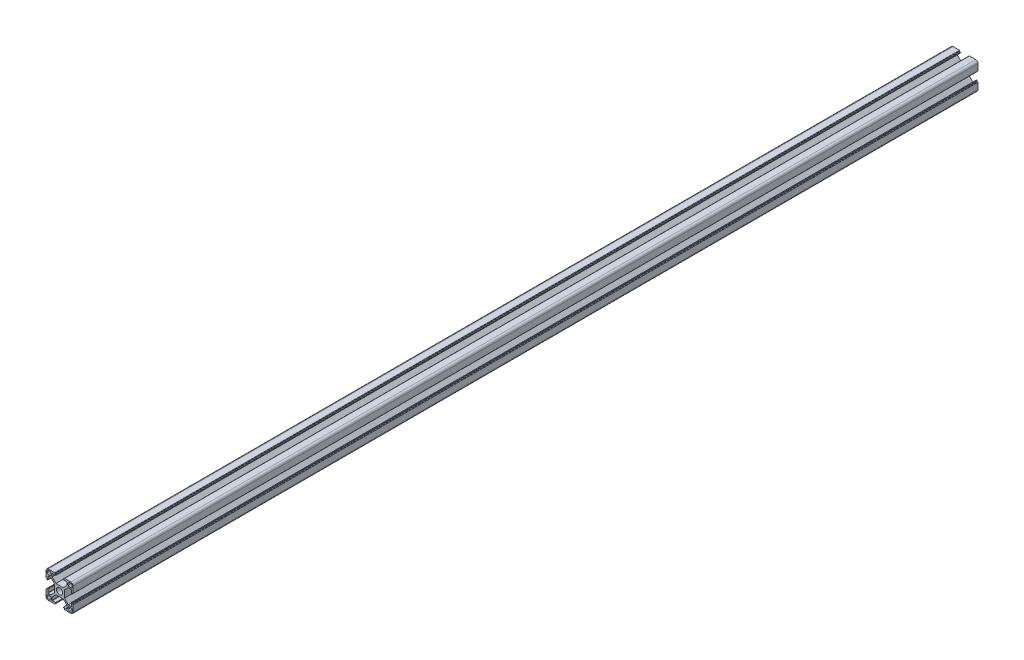
from build123d import *

# Parameters (mm, degrees)
SKETCH_1_R      = 3.4
EXTRUDE_1_DEPTH = 1000


with BuildPart() as part:
    # Эскиз1 → Бобышка-Вытянуть1 (new body)
    with BuildSketch(Plane.XY):
        with BuildLine():
            Line((-15, -8.25), (-15, -12.5))
            ThreePointArc((-15, -12.5), (-14.267766953, -14.267766953), (-12.5, -15))
            Line((-12.5, -15), (-8.25, -15))
            Line((-8.25, -15), (-5.5, -15))
            ThreePointArc((-5.5, -15), (-5.287867966, -14.912132034), (-5.2, -14.7))
            Line((-5.2, -14.7), (-5.2, -14.3))
            ThreePointArc((-5.2, -14.3), (-5.112132034, -14.087867966), (-4.9, -14))
            Line((-4.9, -14), (-4.4, -14))
            ThreePointArc((-4.4, -14), (-4.187867966, -13.912132034), (-4.1, -13.7))
            Line((-4.1, -13.7), (-4.1, -13.3))
            ThreePointArc((-4.1, -13.3), (-4.187867966, -13.087867966), (-4.4, -13))
            Line((-4.4, -13), (-7.95, -13))
            ThreePointArc((-7.95, -13), (-8.162132034, -12.912132034), (-8.25, -12.7))
            Line((-8.25, -12.7), (-8.25, -9.65))
            Line((-8.25, -9.65), (-4, -5.4))
            Line((-4, -5.4), (4, -5.4))
            Line((4, -5.4), (8.25, -9.65))
            Line((8.25, -9.65), (8.25, -12.7))
            ThreePointArc((8.25, -12.7), (8.162132034, -12.912132034), (7.95, -13))
            Line((7.95, -13), (4.4, -13))
            ThreePointArc((4.4, -13), (4.187867966, -13.087867966), (4.1, -13.3))
            Line((4.1, -13.3), (4.1, -13.7))
            ThreePointArc((4.1, -13.7), (4.187867966, -13.912132034), (4.4, -14))
            Line((4.4, -14), (4.9, -14))
            ThreePointArc((4.9, -14), (5.112132034, -14.087867966), (5.2, -14.3))
            Line((5.2, -14.3), (5.2, -14.7))
            ThreePointArc((5.2, -14.7), (5.287867966, -14.912132034), (5.5, -15))
            Line((5.5, -15), (8.25, -15))
            Line((8.25, -15), (12.5, -15))
            ThreePointArc((12.5, -15), (14.267766953, -14.267766953), (15, -12.5))
            Line((15, -12.5), (15, -8.25))
            Line((15, -8.25), (15, -5.5))
            ThreePointArc((15, -5.5), (14.912132034, -5.287867966), (14.7, -5.2))
            Line((14.7, -5.2), (14.3, -5.2))
            ThreePointArc((14.3, -5.2), (14.087867966, -5.112132034), (14, -4.9))
            Line((14, -4.9), (14, -4.4))
            ThreePointArc((14, -4.4), (13.912132034, -4.187867966), (13.7, -4.1))
            Line((13.7, -4.1), (13.3, -4.1))
            ThreePointArc((13.3, -4.1), (13.087867966, -4.187867966), (13, -4.4))
            Line((13, -4.4), (13, -7.95))
            ThreePointArc((13, -7.95), (12.912132034, -8.162132034), (12.7, -8.25))
            Line((12.7, -8.25), (9.65, -8.25))
            Line((9.65, -8.25), (5.4, -4))
            Line((5.4, -4), (5.4, 4))
            Line((5.4, 4), (9.65, 8.25))
            Line((9.65, 8.25), (12.7, 8.25))
            ThreePointArc((12.7, 8.25), (12.912132034, 8.162132034), (13, 7.95))
            Line((13, 7.95), (13, 4.4))
            ThreePointArc((13, 4.4), (13.087867966, 4.187867966), (13.3, 4.1))
            Line((13.3, 4.1), (13.7, 4.1))
            ThreePointArc((13.7, 4.1), (13.912132034, 4.187867966), (14, 4.4))
            Line((14, 4.4), (14, 4.9))
            ThreePointArc((14, 4.9), (14.087867966, 5.112132034), (14.3, 5.2))
            Line((14.3, 5.2), (14.7, 5.2))
            ThreePointArc((14.7, 5.2), (14.912132034, 5.287867966), (15, 5.5))
            Line((15, 5.5), (15, 8.25))
            Line((15, 8.25), (15, 12.5))
            ThreePointArc((15, 12.5), (14.267766953, 14.267766953), (12.5, 15))
            Line((12.5, 15), (8.25, 15))
            Line((8.25, 15), (5.5, 15))
            ThreePointArc((5.5, 15), (5.287867966, 14.912132034), (5.2, 14.7))
            Line((5.2, 14.7), (5.2, 14.3))
            ThreePointArc((5.2, 14.3), (5.112132034, 14.087867966), (4.9, 14))
            Line((4.9, 14), (4.4, 14))
            ThreePointArc((4.4, 14), (4.187867966, 13.912132034), (4.1, 13.7))
            Line((4.1, 13.7), (4.1, 13.3))
            ThreePointArc((4.1, 13.3), (4.187867966, 13.087867966), (4.4, 13))
            Line((4.4, 13), (7.95, 13))
            ThreePointArc((7.95, 13), (8.162132034, 12.912132034), (8.25, 12.7))
            Line((8.25, 12.7), (8.25, 9.65))
            Line((8.25, 9.65), (4, 5.4))
            Line((4, 5.4), (-4, 5.4))
            Line((-4, 5.4), (-8.25, 9.65))
            Line((-8.25, 9.65), (-8.25, 12.7))
            ThreePointArc((-8.25, 12.7), (-8.162132034, 12.912132034), (-7.95, 13))
            Line((-7.95, 13), (-4.4, 13))
            ThreePointArc((-4.4, 13), (-4.187867966, 13.087867966), (-4.1, 13.3))
            Line((-4.1, 13.3), (-4.1, 13.7))
            ThreePointArc((-4.1, 13.7), (-4.187867966, 13.912132034), (-4.4, 14))
            Line((-4.4, 14), (-4.9, 14))
            ThreePointArc((-4.9, 14), (-5.112132034, 14.087867966), (-5.2, 14.3))
            Line((-5.2, 14.3), (-5.2, 14.7))
            ThreePointArc((-5.2, 14.7), (-5.287867966, 14.912132034), (-5.5, 15))
            Line((-5.5, 15), (-8.25, 15))
            Line((-8.25, 15), (-12.5, 15))
            ThreePointArc((-12.5, 15), (-14.267766953, 14.267766953), (-15, 12.5))
            Line((-15, 12.5), (-15, 8.25))
            Line((-15, 8.25), (-15, 5.5))
            ThreePointArc((-15, 5.5), (-14.912132034, 5.287867966), (-14.7, 5.2))
            Line((-14.7, 5.2), (-14.3, 5.2))
            ThreePointArc((-14.3, 5.2), (-14.087867966, 5.112132034), (-14, 4.9))
            Line((-14, 4.9), (-14, 4.4))
            ThreePointArc((-14, 4.4), (-13.912132034, 4.187867966), (-13.7, 4.1))
            Line((-13.7, 4.1), (-13.3, 4.1))
            ThreePointArc((-13.3, 4.1), (-13.087867966, 4.187867966), (-13, 4.4))
            Line((-13, 4.4), (-13, 7.95))
            ThreePointArc((-13, 7.95), (-12.912132034, 8.162132034), (-12.7, 8.25))
            Line((-12.7, 8.25), (-9.65, 8.25))
            Line((-9.65, 8.25), (-5.4, 4))
            Line((-5.4, 4), (-5.4, -4))
            Line((-5.4, -4), (-9.65, -8.25))
            Line((-9.65, -8.25), (-12.7, -8.25))
            ThreePointArc((-12.7, -8.25), (-12.912132034, -8.162132034), (-13, -7.95))
            Line((-13, -7.95), (-13, -4.4))
            ThreePointArc((-13, -4.4), (-13.087867966, -4.187867966), (-13.3, -4.1))
            Line((-13.3, -4.1), (-13.7, -4.1))
            ThreePointArc((-13.7, -4.1), (-13.912132034, -4.187867966), (-14, -4.4))
            Line((-14, -4.4), (-14, -4.9))
            ThreePointArc((-14, -4.9), (-14.087867966, -5.112132034), (-14.3, -5.2))
            Line((-14.3, -5.2), (-14.7, -5.2))
            ThreePointArc((-14.7, -5.2), (-14.912132034, -5.287867966), (-15, -5.5))
            Line((-15, -5.5), (-15, -8.25))
        make_face()
        Circle(SKETCH_1_R, mode=Mode.SUBTRACT)
        with BuildLine():
            Line((-12.45, -9.55), (-10.85, -9.55))
            ThreePointArc((-10.85, -9.55), (-9.930761184, -9.930761184), (-9.55, -10.85))
            Line((-9.55, -10.85), (-9.55, -12.45))
            ThreePointArc((-9.55, -12.45), (-9.930761184, -13.369238816), (-10.85, -13.75))
            Line((-10.85, -13.75), (-12.45, -13.75))
            ThreePointArc((-12.45, -13.75), (-13.369238816, -13.369238816), (-13.75, -12.45))
            Line((-13.75, -12.45), (-13.75, -10.85))
            ThreePointArc((-13.75, -10.85), (-13.369238816, -9.930761184), (-12.45, -9.55))
        make_face(mode=Mode.SUBTRACT)
        with BuildLine():
            Line((-9.55, 12.45), (-9.55, 10.85))
            ThreePointArc((-9.55, 10.85), (-9.930761184, 9.930761184), (-10.85, 9.55))
            Line((-10.85, 9.55), (-12.45, 9.55))
            ThreePointArc((-12.45, 9.55), (-13.369238816, 9.930761184), (-13.75, 10.85))
            Line((-13.75, 10.85), (-13.75, 12.45))
            ThreePointArc((-13.75, 12.45), (-13.369238816, 13.369238816), (-12.45, 13.75))
            Line((-12.45, 13.75), (-10.85, 13.75))
            ThreePointArc((-10.85, 13.75), (-9.930761184, 13.369238816), (-9.55, 12.45))
        make_face(mode=Mode.SUBTRACT)
        with BuildLine():
            Line((12.45, 9.55), (10.85, 9.55))
            ThreePointArc((10.85, 9.55), (9.930761184, 9.930761184), (9.55, 10.85))
            Line((9.55, 10.85), (9.55, 12.45))
            ThreePointArc((9.55, 12.45), (9.930761184, 13.369238816), (10.85, 13.75))
            Line((10.85, 13.75), (12.45, 13.75))
            ThreePointArc((12.45, 13.75), (13.369238816, 13.369238816), (13.75, 12.45))
            Line((13.75, 12.45), (13.75, 10.85))
            ThreePointArc((13.75, 10.85), (13.369238816, 9.930761184), (12.45, 9.55))
        make_face(mode=Mode.SUBTRACT)
        with BuildLine():
            Line((9.55, -12.45), (9.55, -10.85))
            ThreePointArc((9.55, -10.85), (9.930761184, -9.930761184), (10.85, -9.55))
            Line((10.85, -9.55), (12.45, -9.55))
            ThreePointArc((12.45, -9.55), (13.369238816, -9.930761184), (13.75, -10.85))
            Line((13.75, -10.85), (13.75, -12.45))
            ThreePointArc((13.75, -12.45), (13.369238816, -13.369238816), (12.45, -13.75))
            Line((12.45, -13.75), (10.85, -13.75))
            ThreePointArc((10.85, -13.75), (9.930761184, -13.369238816), (9.55, -12.45))
        make_face(mode=Mode.SUBTRACT)
    extrude(amount=EXTRUDE_1_DEPTH)


solid = part.part
